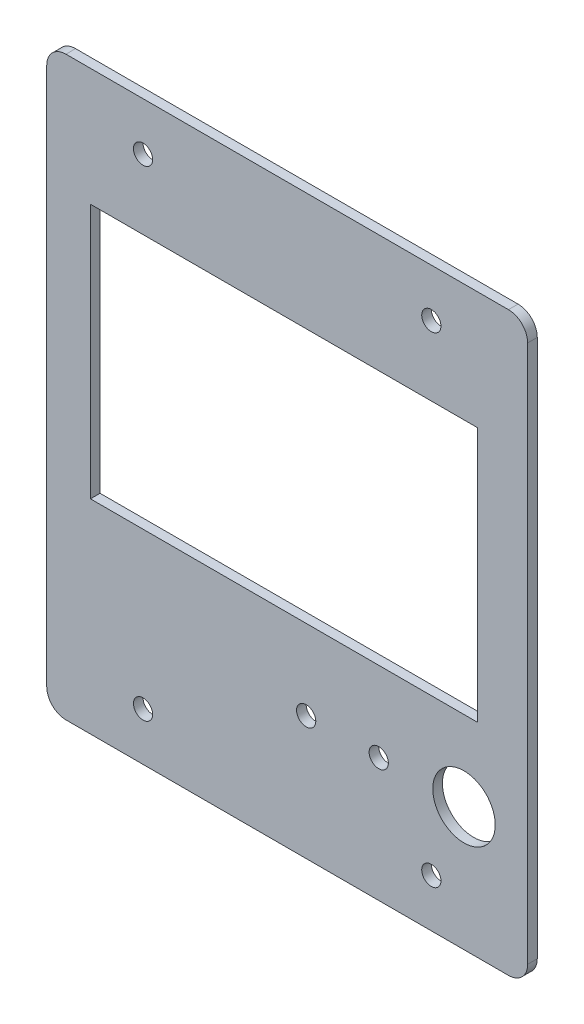
from build123d import *

# Parameters (mm, degrees)
SKETCH1_R           = 2
SKETCH1_R_2         = 6.5
SKETCH1_W           = 80.6
SKETCH1_H           = 53.1
BOSS_EXTRUDE1_DEPTH = 2


with BuildPart() as part:
    # Sketch1 → Boss-Extrude1 (new body)
    with BuildSketch(Plane.XY):
        with BuildLine():
            Line((-46.05, 60), (46.05, 60))
            ThreePointArc((46.05, 60), (48.878427125, 58.828427125), (50.05, 56))
            Line((50.05, 56), (50.05, -56))
            ThreePointArc((50.05, -56), (48.878427125, -58.828427125), (46.05, -60))
            Line((46.05, -60), (-46.05, -60))
            ThreePointArc((-46.05, -60), (-48.878427125, -58.828427125), (-50.05, -56))
            Line((-50.05, -56), (-50.05, 56))
            ThreePointArc((-50.05, 56), (-48.878427125, 58.828427125), (-46.05, 60))
        make_face()
        with Locations((-30, 50)):
            Circle(SKETCH1_R, mode=Mode.SUBTRACT)
        with Locations((-30, -50)):
            Circle(SKETCH1_R, mode=Mode.SUBTRACT)
        with Locations((30, -50)):
            Circle(SKETCH1_R, mode=Mode.SUBTRACT)
        with Locations((30, 50)):
            Circle(SKETCH1_R, mode=Mode.SUBTRACT)
        with Locations((36.8, -34.25)):
            Circle(SKETCH1_R_2, mode=Mode.SUBTRACT)
        with Locations((19.05, -34.25)):
            Circle(SKETCH1_R, mode=Mode.SUBTRACT)
        with Locations((3.95, -34.25)):
            Circle(SKETCH1_R, mode=Mode.SUBTRACT)
        with Locations((-0.65, 8.95)):
            Rectangle(SKETCH1_W, SKETCH1_H, mode=Mode.SUBTRACT)
    extrude(amount=BOSS_EXTRUDE1_DEPTH)


solid = part.part
